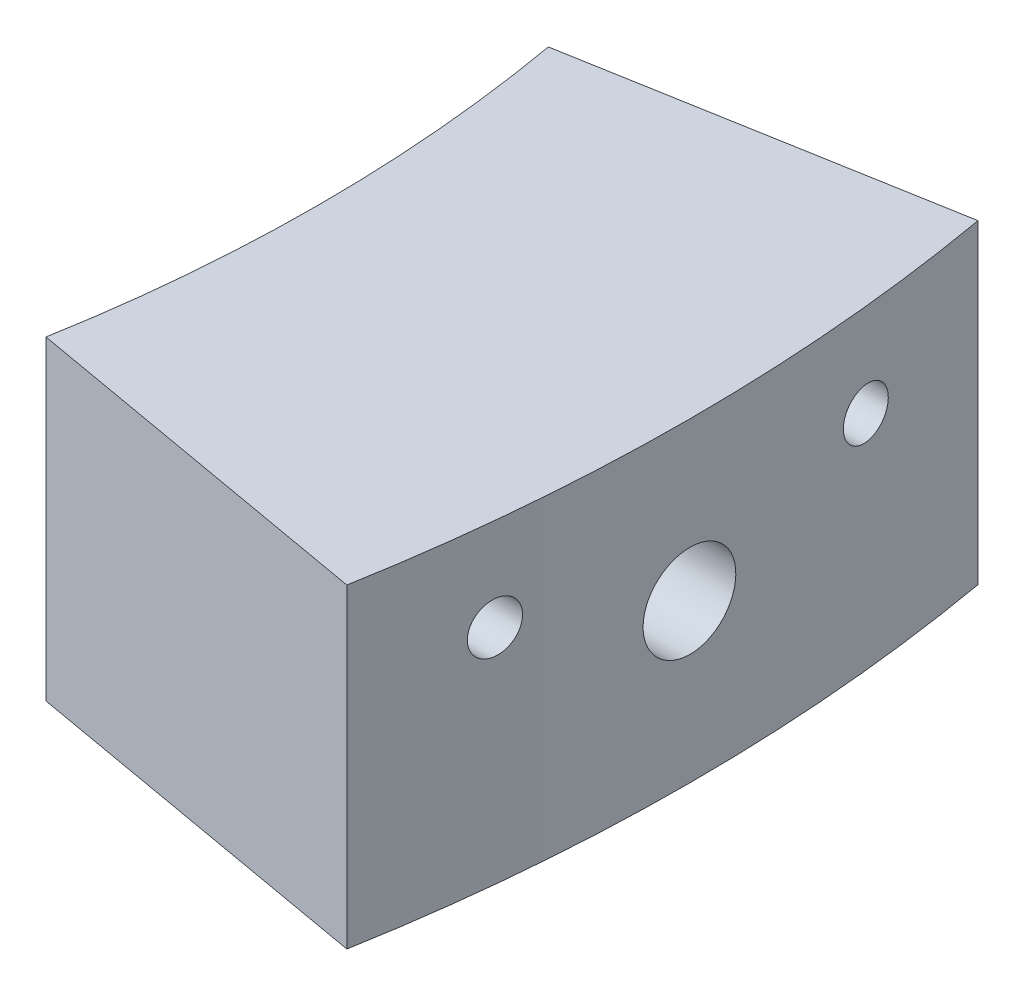
from build123d import *

# Parameters (mm, degrees)
SKETCH1_W          = 20
SKETCH1_H          = 17
REVOLVE1_ANGLE     = 20
SKETCH2_R          = 2.5
SKETCH2_R_2        = 1.35
CUT_EXTRUDE1_DEPTH = 20


with BuildPart() as part:
    # Sketch1 → Revolve1 (revolve, symmetric)
    with BuildSketch(Plane.XY) as revolve1_sk:
        with Locations((88, 8.5)):
            Rectangle(SKETCH1_W, SKETCH1_H)
    revolve(axis=Axis((0, -55, 0), (0, 1, 0)), revolution_arc=REVOLVE1_ANGLE / 2)
    revolve(revolve1_sk.sketch, axis=Axis((0, -55, 0), (0, -1, 0)), revolution_arc=REVOLVE1_ANGLE / 2)

    # Sketch2 → Cut-Extrude1 (cut)
    with BuildSketch(Plane(origin=(80, 0, 0), x_dir=(0, 0, -1), z_dir=(1, 0, 0))):
        with Locations((0, 8.5)):
            Circle(SKETCH2_R)
        with Locations((-10, 12)):
            Circle(SKETCH2_R_2)
        with Locations((10, 12)):
            Circle(SKETCH2_R_2)
    extrude(amount=CUT_EXTRUDE1_DEPTH, mode=Mode.SUBTRACT)


solid = part.part
